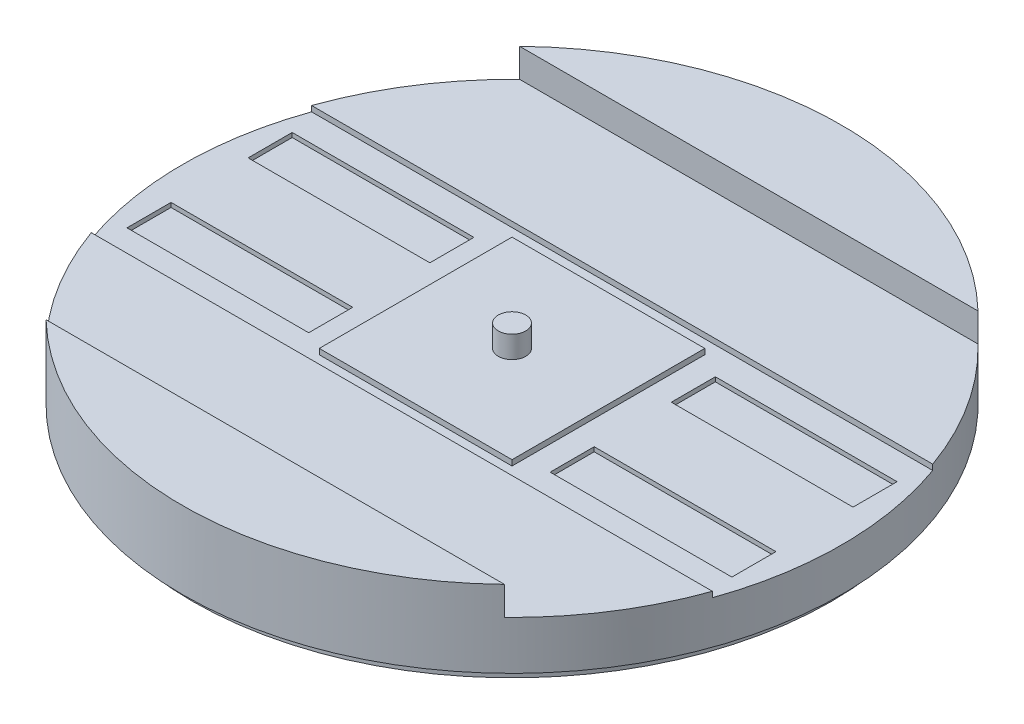
from build123d import *

# Parameters (mm, degrees)
SKETCH2_R           = 76
BOSS_EXTRUDE1_DEPTH = 17.78
CUT_EXTRUDE3_DEPTH  = 6.604
CUT_EXTRUDE5_DEPTH  = 1.27
SKETCH10_W          = 41.91
SKETCH10_H          = 10.16
CUT_EXTRUDE6_DEPTH  = 1.016
SKETCH11_W          = 44.45
SKETCH11_H          = 44.45
BOSS_EXTRUDE2_DEPTH = 1.27
SKETCH14_R          = 3.175
BOSS_EXTRUDE4_DEPTH = 5.08
SKETCH15_R          = 73.66
BOSS_EXTRUDE5_DEPTH = 2.54
SKETCH16_R          = 3.175
CUT_EXTRUDE8_DEPTH  = 12.7


with BuildPart() as part:
    # Sketch2 → Boss-Extrude1 (new body)
    with BuildSketch(Plane(origin=(0, 0, 0), x_dir=(1, 0, 0), z_dir=(0, 1, 0))):
        Circle(SKETCH2_R)
    extrude(amount=BOSS_EXTRUDE1_DEPTH)

    # Sketch6 → Cut-Extrude3 (cut)
    with BuildSketch(Plane(origin=(0, 17.78, 0), x_dir=(1, 0, 0), z_dir=(0, 1, 0))):
        with BuildLine():
            Line((-76, 54.61), (76, 54.61))
            ThreePointArc((76, 54.61), (130.61, 0), (76, -54.61))
            Line((76, -54.61), (-76, -54.61))
            ThreePointArc((-76, -54.61), (-130.61, 0), (-76, 54.61))
        make_face()
    extrude(amount=-CUT_EXTRUDE3_DEPTH, mode=Mode.SUBTRACT)

    # Sketch9 → Cut-Extrude5 (cut)
    with BuildSketch(Plane(origin=(0, 11.176, 0), x_dir=(1, 0, 0), z_dir=(0, 1, 0))):
        with BuildLine():
            Line((-76, 25.4), (-25.4, 25.4))
            Line((-25.4, 25.4), (25.4, 25.4))
            Line((25.4, 25.4), (76, 25.4))
            ThreePointArc((76, 25.4), (101.4, 0), (76, -25.4))
            Line((76, -25.4), (25.4, -25.4))
            Line((25.4, -25.4), (-25.4, -25.4))
            Line((-25.4, -25.4), (-76, -25.4))
            ThreePointArc((-76, -25.4), (-101.4, 0), (-76, 25.4))
        make_face()
    extrude(amount=-CUT_EXTRUDE5_DEPTH, mode=Mode.SUBTRACT)

    # Sketch10 → Cut-Extrude6 (cut)
    with BuildSketch(Plane(origin=(0, 9.906, 0), x_dir=(1, 0, 0), z_dir=(0, 1, 0))):
        with Locations((-48.79885899, 13.97)):
            Rectangle(SKETCH10_W, SKETCH10_H)
        with Locations((-48.79885899, -13.97)):
            Rectangle(SKETCH10_W, SKETCH10_H)
        with Locations((48.79885899, -13.97)):
            Rectangle(SKETCH10_W, SKETCH10_H)
        with Locations((48.79885899, 13.97)):
            Rectangle(SKETCH10_W, SKETCH10_H)
    extrude(amount=-CUT_EXTRUDE6_DEPTH, mode=Mode.SUBTRACT)

    # Sketch11 → Boss-Extrude2 (add)
    with BuildSketch(Plane(origin=(0, 9.906, 0), x_dir=(1, 0, 0), z_dir=(0, 1, 0))):
        Rectangle(SKETCH11_W, SKETCH11_H)
    extrude(amount=BOSS_EXTRUDE2_DEPTH)

    # Sketch14 → Boss-Extrude4 (add)
    with BuildSketch(Plane(origin=(0, 11.176, 0), x_dir=(1, 0, 0), z_dir=(0, 1, 0))):
        Circle(SKETCH14_R)
    extrude(amount=BOSS_EXTRUDE4_DEPTH)

    # Sketch15 → Boss-Extrude5 (add)
    with BuildSketch(Plane.XZ):
        Circle(SKETCH15_R)
    extrude(amount=BOSS_EXTRUDE5_DEPTH)

    # Sketch16 → Cut-Extrude8 (cut)
    with BuildSketch(Plane.XZ.offset(2.54)):
        with Locations((0, 64.77)):
            Circle(SKETCH16_R)
        with Locations((0, -64.77)):
            Circle(SKETCH16_R)
    extrude(amount=-CUT_EXTRUDE8_DEPTH, mode=Mode.SUBTRACT)


solid = part.part
